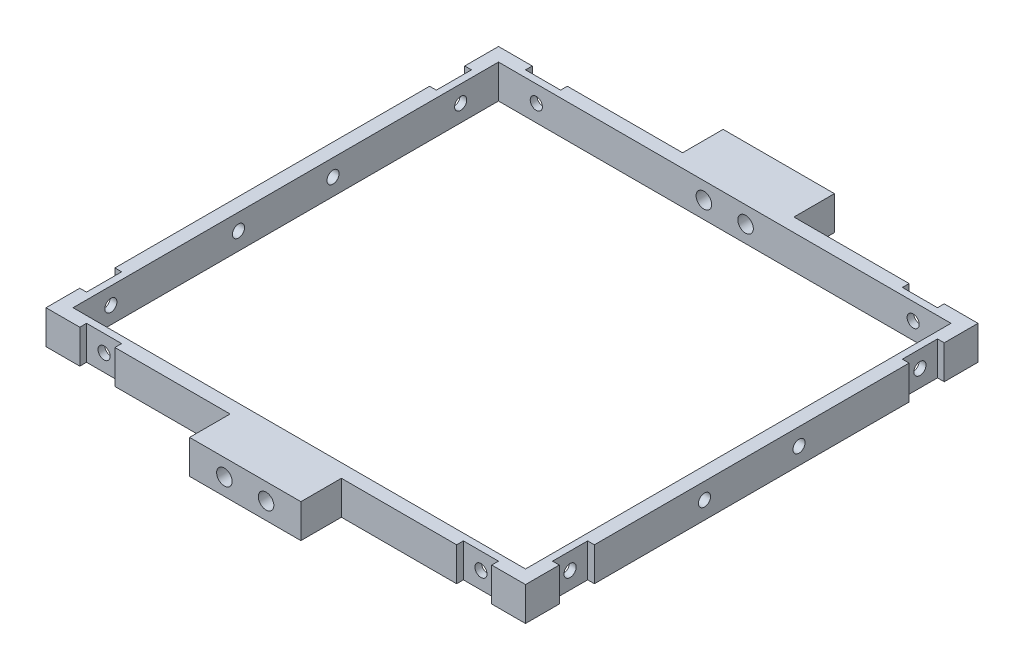
from build123d import *

# Parameters (mm, degrees)
SKETCH1_W           = 71
SKETCH1_H           = 67
SKETCH1_W_2         = 67
SKETCH1_H_2         = 63
BOSS_EXTRUDE1_DEPTH = 5
SKETCH2_R           = 0.9
CUT_EXTRUDE1_DEPTH  = 121
SKETCH3_R           = 1
CUT_EXTRUDE2_DEPTH  = 0.01
SKETCH9_W           = 5.2
SKETCH9_H           = 5
CUT_EXTRUDE6_DEPTH  = 1
SKETCH10_W          = 5.2
SKETCH10_H          = 5
CUT_EXTRUDE7_DEPTH  = 1
SKETCH11_R          = 0.9
CUT_EXTRUDE8_DEPTH  = 81
SKETCH12_R          = 0.9
CUT_EXTRUDE9_DEPTH  = 81
SKETCH14_R          = 1.15
CUT_EXTRUDE10_DEPTH = 79
SKETCH15_W          = 16.483338106
SKETCH15_H          = 5
BOSS_EXTRUDE2_DEPTH = 6
SKETCH16_R          = 1.15
CUT_EXTRUDE11_DEPTH = 30
SKETCH17_R          = 1.15
CUT_EXTRUDE12_DEPTH = 30


with BuildPart() as part:
    # Sketch1 → Boss-Extrude1 (new body)
    with BuildSketch(Plane(origin=(0, 0, 0), x_dir=(1, 0, 0), z_dir=(0, 1, 0))):
        Rectangle(SKETCH1_W, SKETCH1_H)
        Rectangle(SKETCH1_W_2, SKETCH1_H_2, mode=Mode.SUBTRACT)
    extrude(amount=BOSS_EXTRUDE1_DEPTH)

    # Sketch2 → Cut-Extrude1 (cut)
    with BuildSketch(Plane(origin=(35.5, 0, 0), x_dir=(0, 0, -1), z_dir=(1, 0, 0))):
        with Locations((-6.999701476, 2.591425228)):
            Circle(SKETCH2_R)
        with Locations((7, 2.5)):
            Circle(SKETCH2_R)
    extrude(amount=-CUT_EXTRUDE1_DEPTH, mode=Mode.SUBTRACT)

    # Sketch3 → Cut-Extrude2 (cut)
    with BuildSketch(Plane.XY.offset(33.5)):
        with Locations((0, 2.5)):
            Circle(SKETCH3_R)
    extrude(amount=-CUT_EXTRUDE2_DEPTH, mode=Mode.SUBTRACT)

    # Sketch9 → Cut-Extrude6 (cut)
    with BuildSketch(Plane.XY.offset(33.5)):
        with Locations((-27.9, 2.5)):
            Rectangle(SKETCH9_W, SKETCH9_H)
        with Locations((27.9, 2.5)):
            Rectangle(SKETCH9_W, SKETCH9_H)
    cut_extrude6 = extrude(amount=-CUT_EXTRUDE6_DEPTH, mode=Mode.SUBTRACT)

    # Sketch10 → Cut-Extrude7 (cut)
    with BuildSketch(Plane(origin=(35.5, 0, 0), x_dir=(0, 0, -1), z_dir=(1, 0, 0))):
        with Locations((-25.9, 2.5)):
            Rectangle(SKETCH10_W, SKETCH10_H)
        with Locations((25.9, 2.5)):
            Rectangle(SKETCH10_W, SKETCH10_H)
    cut_extrude7 = extrude(amount=-CUT_EXTRUDE7_DEPTH, mode=Mode.SUBTRACT)

    # Mirror2: Cut-Extrude7 across plane
    add(cut_extrude7.mirror(Plane(origin=(0, 0, 0), x_dir=(0, 0, 1), z_dir=(1, 0, 0))), mode=Mode.SUBTRACT)

    # Mirror3: Cut-Extrude6 across plane
    add(cut_extrude6.mirror(Plane.XY), mode=Mode.SUBTRACT)

    # Sketch11 → Cut-Extrude8 (cut)
    with BuildSketch(Plane(origin=(34.5, 0, 0), x_dir=(0, 0, -1), z_dir=(1, 0, 0))):
        with Locations((25.9, 2.5)):
            Circle(SKETCH11_R)
        with Locations((-25.9, 2.5)):
            Circle(SKETCH11_R)
    extrude(amount=-CUT_EXTRUDE8_DEPTH, mode=Mode.SUBTRACT)

    # Sketch12 → Cut-Extrude9 (cut)
    with BuildSketch(Plane.XY.offset(32.5)):
        with Locations((27.9, 2.5)):
            Circle(SKETCH12_R)
        with Locations((-27.9, 2.5)):
            Circle(SKETCH12_R)
    extrude(amount=-CUT_EXTRUDE9_DEPTH, mode=Mode.SUBTRACT)

    # Sketch14 → Cut-Extrude10 (cut)
    with BuildSketch(Plane(origin=(0, 0, -33.5), x_dir=(-1, 0, 0), z_dir=(0, 0, -1))):
        with Locations((-3.085, 2.5)):
            Circle(SKETCH14_R)
        with Locations((3.088228318, 2.5)):
            Circle(SKETCH14_R)
    cut_extrude10 = extrude(amount=-CUT_EXTRUDE10_DEPTH, mode=Mode.SUBTRACT)

    # Sketch15 → Boss-Extrude2 (add)
    with BuildSketch(Plane(origin=(0, 0, -33.5), x_dir=(-1, 0, 0), z_dir=(0, 0, -1))):
        with Locations((0, 2.5)):
            Rectangle(SKETCH15_W, SKETCH15_H)
    boss_extrude2 = extrude(amount=BOSS_EXTRUDE2_DEPTH)

    # Sketch16 → Cut-Extrude11 (cut)
    with BuildSketch(Plane.XY.offset(-31.5)):
        with Locations((-3.088228318, 2.5)):
            Circle(SKETCH16_R)
        with Locations((3.085, 2.5)):
            Circle(SKETCH16_R)
    extrude(amount=-CUT_EXTRUDE11_DEPTH, mode=Mode.SUBTRACT)

    # Mirror4: Cut-Extrude10, Boss-Extrude2 across plane
    add(cut_extrude10.mirror(Plane.XY), mode=Mode.SUBTRACT)
    add(boss_extrude2.mirror(Plane.XY))

    # Sketch17 → Cut-Extrude12 (cut)
    with BuildSketch(Plane(origin=(0, 0, 31.5), x_dir=(-1, 0, 0), z_dir=(0, 0, -1))):
        with Locations((-3.085, 2.5)):
            Circle(SKETCH17_R)
        with Locations((3.088228318, 2.5)):
            Circle(SKETCH17_R)
    extrude(amount=-CUT_EXTRUDE12_DEPTH, mode=Mode.SUBTRACT)


solid = part.part
